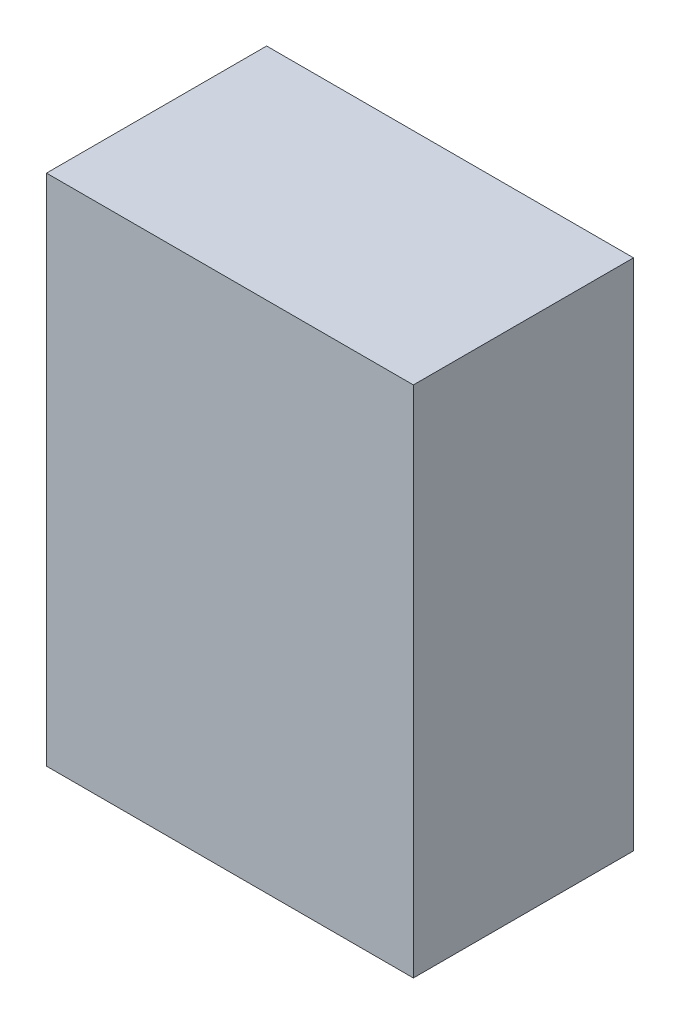
from build123d import *

# Parameters (mm, degrees)
ESQUISSE1_W        = 25
ESQUISSE1_H        = 35
BOSS_EXTRU_1_DEPTH = 15


with BuildPart() as part:
    # Esquisse1 → Boss.-Extru.1 (new body)
    with BuildSketch(Plane.XY):
        with Locations((12.5, -17.5)):
            Rectangle(ESQUISSE1_W, ESQUISSE1_H)
    extrude(amount=BOSS_EXTRU_1_DEPTH)


solid = part.part
